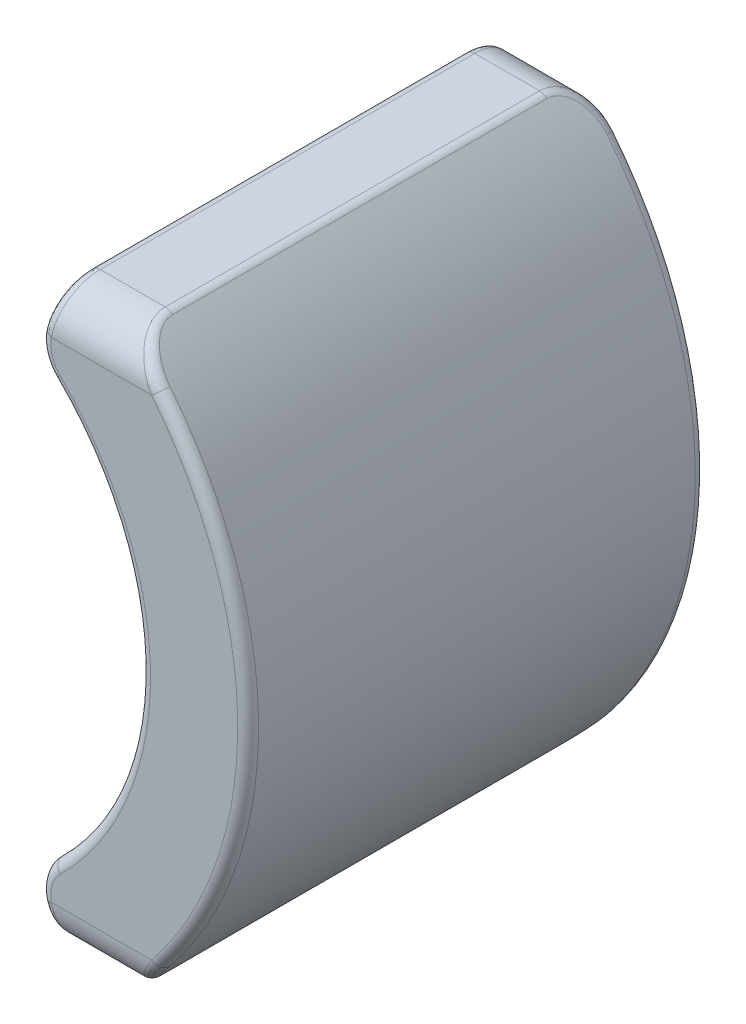
from build123d import *

# Parameters (mm, degrees)
BOSS_EXTRUDE1_DEPTH = 11
FILLET1_R           = 1
FILLET2_R           = 1
FILLET3_R           = 0.25


with BuildPart() as part:
    # Sketch1 → Boss-Extrude1 (new body)
    with BuildSketch(Plane.XY):
        with BuildLine():
            Line((6.738137725, -6.88), (4.878137725, -6.88))
            Line((4.878137725, -6.88), (4.531835438, -5.38))
            ThreePointArc((4.531835438, -5.38), (7.034339517, 0), (4.531835438, 5.38))
            Line((4.531835438, 5.38), (4.878137725, 6.88))
            Line((4.878137725, 6.88), (6.738137725, 6.88))
            ThreePointArc((6.738137725, 6.88), (9.63, 0), (6.738137725, -6.88))
        make_face()
    extrude(amount=BOSS_EXTRUDE1_DEPTH)

    # Fillet1
    fillet1_edges = [part.edges().sort_by_distance(p)[0] for p in [
        (4.531835438, -5.38, 5.5),
        (4.531835438, 5.38, 5.5),
    ]]
    fillet(fillet1_edges, radius=FILLET1_R)

    # Fillet2
    fillet2_edges = [part.edges().sort_by_distance(p)[0] for p in [
        (5.808137725, -6.88, 0),
        (5.808137725, -6.88, 11),
        (5.808137725, 6.88, 11),
        (5.808137725, 6.88, 0),
    ]]
    fillet(fillet2_edges, radius=FILLET2_R)

    # Fillet3
    fillet3_edges = [part.edges().sort_by_distance(p)[0] for p in [
        (7.034339517, 0, 0),
        (4.687877266, 5.411310183, 0),
        (7.034339517, 0, 11),
        (4.687877266, -5.411310183, 11),
        (6.738137725, -6.88, 5.5),
        (4.878137725, -6.88, 5.5),
        (9.63, 0, 0),
        (6.738137725, 6.88, 5.5),
        (9.63, 0, 11),
        (7.064336587, 6.544619823, 0.252818297),
        (7.064336587, 6.544619823, 10.747181703),
        (7.064336589, -6.544619821, 10.747181705),
        (7.064336577, -6.544619807, 0.2528183),
        (4.687877266, -5.411310183, 0),
        (4.655934772, -5.914769545, 10.999395357),
        (4.655934772, -5.914769545, 0.000604643),
        (4.815123489, -6.607055355, 10.686578845),
        (4.815123489, -6.607055355, 0.313421155),
        (4.687877266, 5.411310183, 11),
        (4.655934776, 5.914769544, 0.00060465),
        (4.655934776, 5.914769544, 10.99939535),
        (4.878137725, 6.88, 5.5),
        (4.815123489, 6.607055355, 0.313421155),
        (4.815123489, 6.607055355, 10.686578845),
    ]]
    fillet(fillet3_edges, radius=FILLET3_R)


solid = part.part
